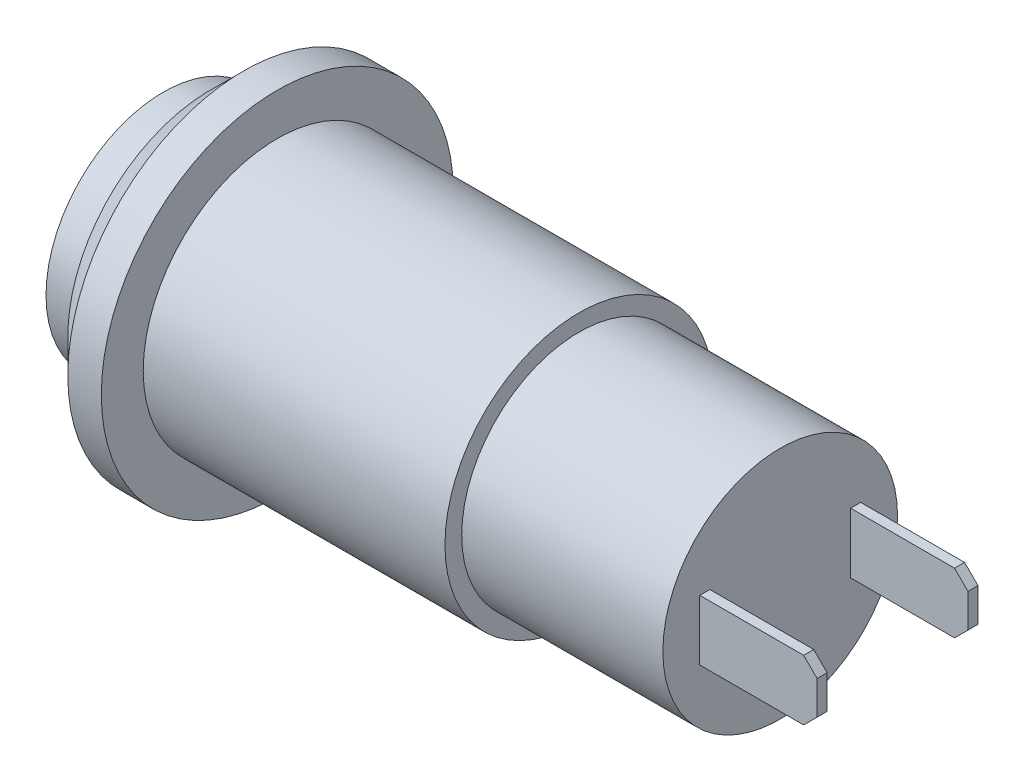
from build123d import *

# Parameters (mm, degrees)
CHAMFER1_SIZE       = 1
SKETCH2_W           = 0.3
SKETCH2_H           = 1.8
BOSS_EXTRUDE1_DEPTH = 3.5
CHAMFER2_SIZE       = 0.4


with BuildPart() as part:
    # Sketch1 → Revolve1 (revolve)
    with BuildSketch(Plane.XY):
        Polygon((18.4, 0), (18.4, 3.5), (12.4, 3.5), (12.4, 4), (3.4, 4), (3.4, 5.25), (1.4, 5.25), (1.4, 3.5), (0, 3.5), (0, 0), align=None)
    revolve(axis=Axis((0, 0, 0), (1, 0, 0)))

    # Chamfer1
    chamfer1_edges = [part.edges().sort_by_distance(p)[0] for p in [
        (1.4, -5.25, 0),
    ]]
    chamfer(chamfer1_edges, length=CHAMFER1_SIZE)

    # Sketch2 → Boss-Extrude1 (add)
    with BuildSketch(Plane(origin=(18.4, 0, 0), x_dir=(0, 0, -1), z_dir=(1, 0, 0))):
        with Locations((-2.25, 0)):
            Rectangle(SKETCH2_W, SKETCH2_H)
        with Locations((2.25, 0)):
            Rectangle(SKETCH2_W, SKETCH2_H)
    extrude(amount=BOSS_EXTRUDE1_DEPTH)

    # Chamfer2
    chamfer2_edges = [part.edges().sort_by_distance(p)[0] for p in [
        (21.9, 0.9, 2.25),
        (21.9, -0.9, 2.25),
        (21.9, 0.9, -2.25),
        (21.9, -0.9, -2.25),
    ]]
    chamfer(chamfer2_edges, length=CHAMFER2_SIZE)


solid = part.part
